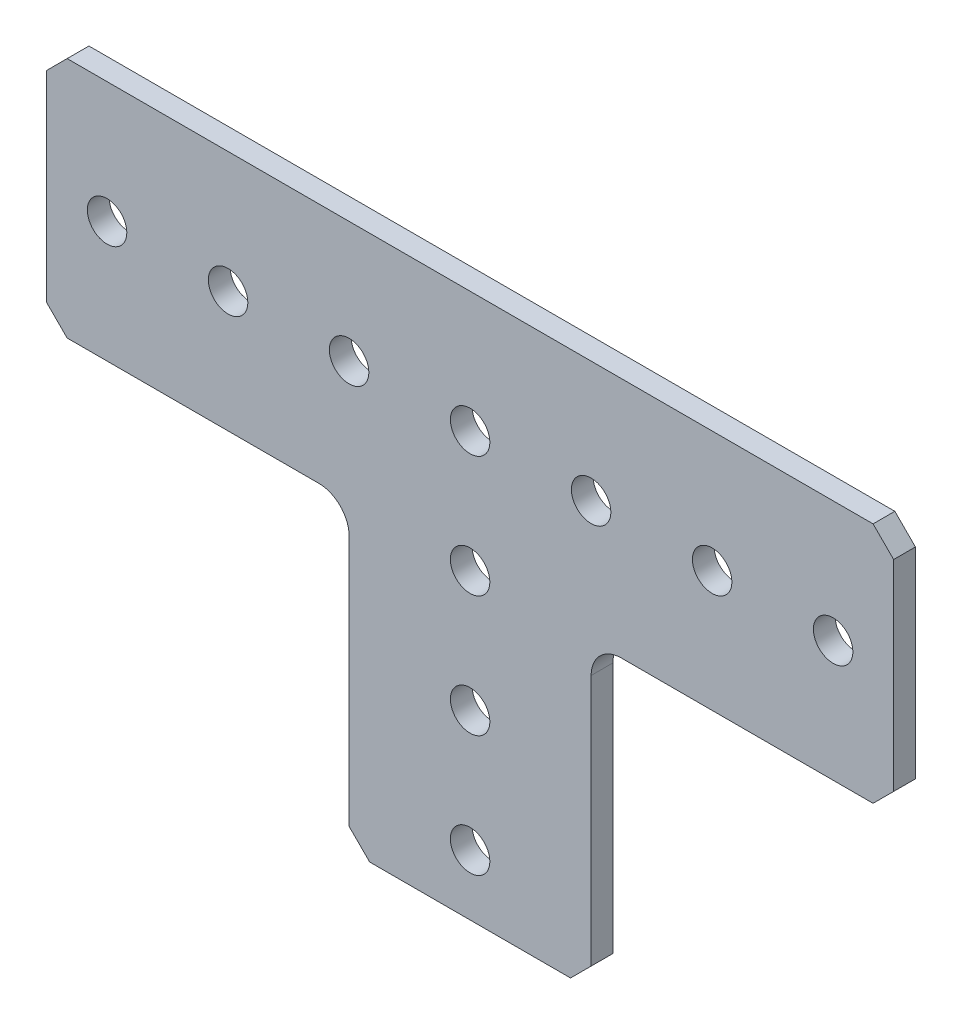
from build123d import *

# Parameters (mm, degrees)
SKETCH1_R           = 2.0701
BOSS_EXTRUDE1_DEPTH = 2.286


with BuildPart() as part:
    # Sketch1 → Boss-Extrude1 (new body)
    with BuildSketch(Plane(origin=(0, 0, 0), x_dir=(-1, 0, 0), z_dir=(0, 0, -1))):
        with BuildLine():
            Line((-12.7, -29.591), (-10.541, -31.75))
            Line((-10.541, -31.75), (10.541, -31.75))
            Line((10.541, -31.75), (12.7, -29.591))
            Line((12.7, -29.591), (12.7, -3.175))
            ThreePointArc((12.7, -3.175), (13.62993597, -0.92993597), (15.875, 0))
            Line((15.875, 0), (42.291, 0))
            Line((42.291, 0), (44.45, 2.159))
            Line((44.45, 2.159), (44.45, 23.241))
            Line((44.45, 23.241), (42.291, 25.4))
            Line((42.291, 25.4), (-42.291, 25.4))
            Line((-42.291, 25.4), (-44.45, 23.241))
            Line((-44.45, 23.241), (-44.45, 2.159))
            Line((-44.45, 2.159), (-42.291, 0))
            Line((-42.291, 0), (-15.875, 0))
            ThreePointArc((-15.875, 0), (-13.62993597, -0.92993597), (-12.7, -3.175))
            Line((-12.7, -3.175), (-12.7, -29.591))
        make_face()
        with Locations((0, -12.7)):
            Circle(SKETCH1_R, mode=Mode.SUBTRACT)
        with Locations((-38.1, 12.7)):
            Circle(SKETCH1_R, mode=Mode.SUBTRACT)
        with Locations((-12.7, 12.7)):
            Circle(SKETCH1_R, mode=Mode.SUBTRACT)
        with Locations((12.7, 12.7)):
            Circle(SKETCH1_R, mode=Mode.SUBTRACT)
        with Locations((25.4, 12.7)):
            Circle(SKETCH1_R, mode=Mode.SUBTRACT)
        with Locations((38.1, 12.7)):
            Circle(SKETCH1_R, mode=Mode.SUBTRACT)
        with Locations((0, -25.4)):
            Circle(SKETCH1_R, mode=Mode.SUBTRACT)
        with Locations((0, 12.7)):
            Circle(SKETCH1_R, mode=Mode.SUBTRACT)
        with Locations((-25.4, 12.7)):
            Circle(SKETCH1_R, mode=Mode.SUBTRACT)
        Circle(SKETCH1_R, mode=Mode.SUBTRACT)
    extrude(amount=-BOSS_EXTRUDE1_DEPTH)


solid = part.part
